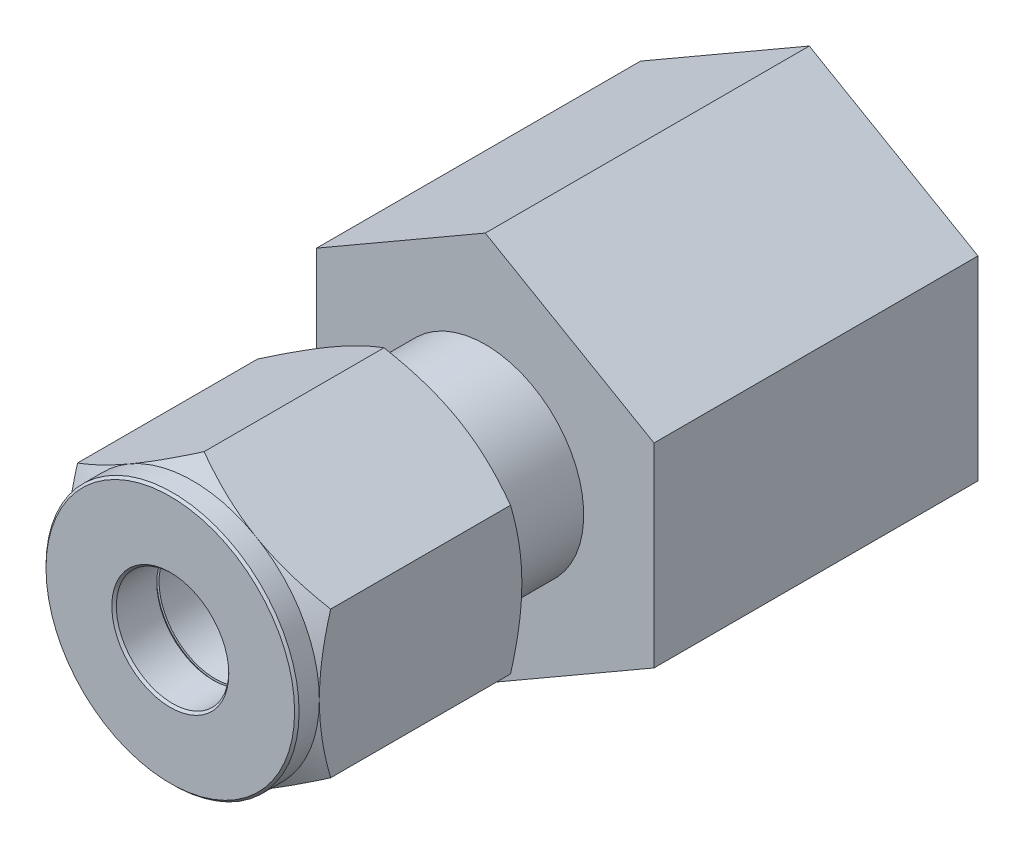
from build123d import *

# Parameters (mm, degrees)
BOSS_EXTRUDE1_DEPTH = 12.7
CHAMFER1_SIZE       = 0.127
SKETCH4_W           = 10.414
SKETCH4_H           = 5.55625
BOSS_EXTRUDE2_DEPTH = 18.288


with BuildPart() as part:
    # Sketch2 → Boss-Extrude1 (new body)
    with BuildSketch(Plane.XY):
        Polygon((0, 8.248891971), (-7.14375, 4.124445986), (-7.14375, -4.124445986), (0, -8.248891971), (7.14375, -4.124445986), (7.14375, 4.124445986), align=None)
    extrude(amount=-BOSS_EXTRUDE1_DEPTH)

    # Sketch3 → Cut-Revolve1 (revolve, cut)
    with BuildSketch(Plane(origin=(0, 0, 0), x_dir=(0, 0, -1), z_dir=(1, 0, 0))):
        Polygon((0, 8.248891971), (0, 7.14375), (1.27, 7.14375), (1.908054014, 8.248891971), (12.061945986, 8.248891971), (12.7, 7.14375), (12.7, 8.248891971), (12.7, 9.354033942), (0, 9.354033942), align=None)
        Polygon((0, 3.175), (0, 0), (12.7, 0), (12.7, 5.55625), (5.08, 5.55625), (5.08, 4.92125), (2.54, 4.92125), (2.54, 4.28625), (2.54, 3.175), align=None)
    revolve(axis=Axis((0, 0, 0), (0, 0, -1)), mode=Mode.SUBTRACT)

    # Chamfer1
    chamfer1_edges = [part.edges().sort_by_distance(p)[0] for p in [
        (0, -7.14375, 0),
        (0, -3.175, -2.54),
        (0, -3.175, 0),
    ]]
    chamfer(chamfer1_edges, length=CHAMFER1_SIZE)


with BuildPart() as body_2:
    # Sketch4 → Revolve1 (revolve)
    with BuildSketch(Plane(origin=(0, 0, 0), x_dir=(0, 0, -1), z_dir=(1, 0, 0))):
        with Locations((12.573, 2.778125)):
            Rectangle(SKETCH4_W, SKETCH4_H)
    revolve(axis=Axis((0, 0, -17.78), (0, 0, 1)))

    # Sketch7 → Boss-Extrude2 (add)
    with BuildSketch(Plane(origin=(0, 0, -17.78), x_dir=(-1, 0, 0), z_dir=(0, 0, -1))):
        Polygon((0, 10.998522628), (-9.525, 5.499261314), (-9.525, -5.499261314), (0, -10.998522628), (9.525, -5.499261314), (9.525, 5.499261314), align=None)
    extrude(amount=BOSS_EXTRUDE2_DEPTH)


with BuildPart() as body_3:
    # Sketch9 → Revolve2 (revolve)
    with BuildSketch(Plane(origin=(0, 0, 0), x_dir=(0, 0, -1), z_dir=(1, 0, 0))):
        Polygon((4.445, 4.699), (4.445, 3.8608), (5.1308, 3.175), (9.3218, 3.175), (9.3218, 3.6068), align=None)
    revolve(axis=Axis((0, 0, 0), (0, 0, -1)))


with BuildPart() as body_4:
    # Sketch10 → Revolve3 (revolve)
    with BuildSketch(Plane(origin=(0, 0, 0), x_dir=(0, 0, -1), z_dir=(1, 0, 0))):
        Polygon((2.54, 4.6609), (3.556, 4.6609), (3.556, 3.8608), (4.445, 3.8608), (5.1308, 3.175), (2.54, 3.175), align=None)
    revolve(axis=Axis((0, 0, 0), (0, 0, -1)))


with BuildPart() as body_5:
    # Sketch11 → Revolve4 (revolve)
    with BuildSketch(Plane(origin=(0, 0, 0), x_dir=(0, 0, -1), z_dir=(1, 0, 0))):
        Polygon((25.86228, 0), (36.068, 0), (36.068, 6.858), (25.86228, 6.540243957), align=None)
    revolve(axis=Axis((0, 0, -25.86228), (0, 0, -1)))


with BuildPart() as body_2_1:
    add(body_2.part)

    # Combine1: cut body 5
    add(body_5.part, mode=Mode.SUBTRACT)


solid = Compound([part.part, body_3.part, body_4.part, body_2_1.part])
